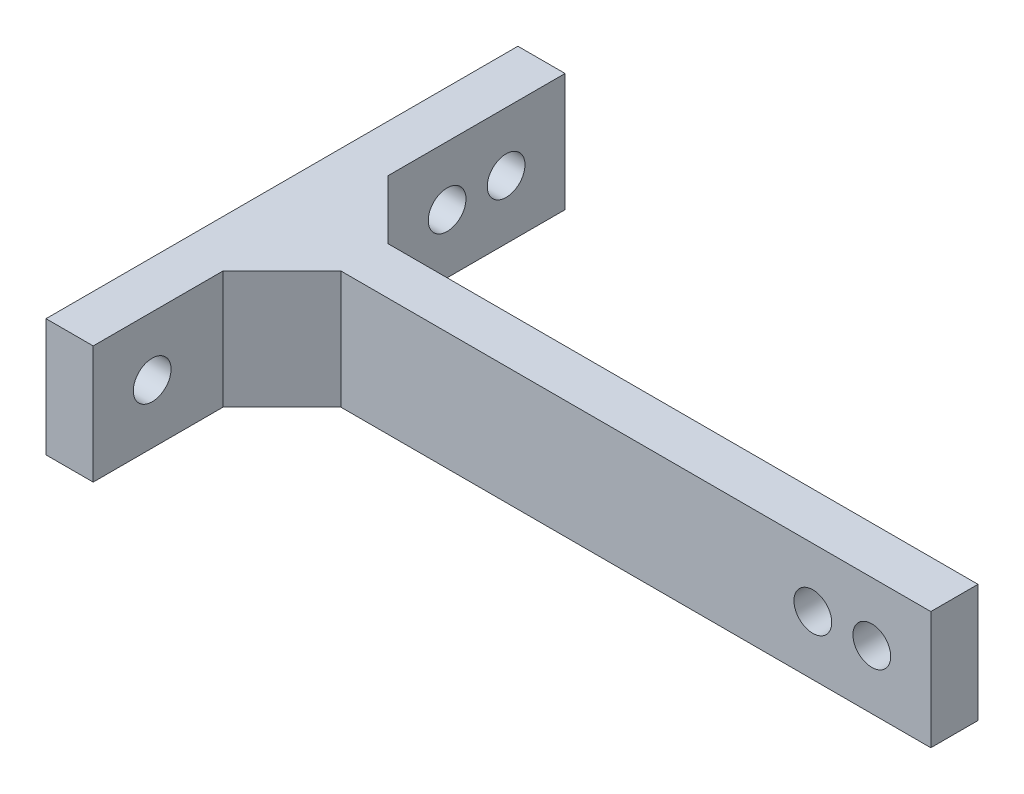
from build123d import *

# Parameters (mm, degrees)
SKETCH_1_W          = 55
SKETCH_1_H          = 10
EXTRUDE_1_DEPTH     = 4
SKETCH_2_W          = 40
SKETCH_2_H          = 10
EXTRUDE_2_DEPTH     = 4
EXTRUDE_3_DEPTH     = 10
EXTRUDE_5_DEPTH     = 10
SKETCH_4_R          = 1.6
CUT_EXTRUDE_1_DEPTH = 5
SKETCH_7_R          = 1.6
CUT_EXTRUDE_2_DEPTH = 4


with BuildPart() as part:
    # ｽｹｯﾁ1 → ﾎﾞｽ - 押し出し1 (new body)
    with BuildSketch(Plane.XY):
        with Locations((4.479686187, -2.540603248)):
            Rectangle(SKETCH_1_W, SKETCH_1_H)
    extrude(amount=EXTRUDE_1_DEPTH)

    # ｽｹｯﾁ2 → ﾎﾞｽ - 押し出し2 (add)
    with BuildSketch(Plane.ZY.offset(23.020313813)):
        with Locations((0, -2.540603248)):
            Rectangle(SKETCH_2_W, SKETCH_2_H)
    extrude(amount=EXTRUDE_2_DEPTH)

    # ｽｹｯﾁ3 → ﾎﾞｽ - 押し出し3 (add)
    with BuildSketch(Plane(origin=(0, 2.459396752, 0), x_dir=(1, 0, 0), z_dir=(0, 1, 0))):
        Polygon((-23.020313813, 5), (-18.020313813, 0), (-23.020313813, 0), align=None)
    extrude(amount=-EXTRUDE_3_DEPTH)

    # ｽｹｯﾁ6 → ﾎﾞｽ - 押し出し5 (add)
    with BuildSketch(Plane.XZ.offset(7.540603248)):
        Polygon((-23.020313813, 9), (-18.020313813, 4), (31.979686187, 4), (31.979686187, 0), (-18.020313813, 0), (-23.020313813, -5), (-23.020313813, -20), (-27.020313813, -20), (-27.020313813, 20), (-23.020313813, 20), align=None)
    extrude(amount=-EXTRUDE_5_DEPTH)

    # ｽｹｯﾁ4 → ｶｯﾄ - 押し出し1 (cut)
    with BuildSketch(Plane.XY.offset(4)):
        with Locations((26.979686187, -2.540603248)):
            Circle(SKETCH_4_R)
        with Locations((21.979686187, -2.540603248)):
            Circle(SKETCH_4_R)
    extrude(amount=-CUT_EXTRUDE_1_DEPTH, mode=Mode.SUBTRACT)

    # ｽｹｯﾁ7 → ｶｯﾄ - 押し出し2 (cut)
    with BuildSketch(Plane(origin=(-23.020313813, 0, 0), x_dir=(0, 0, -1), z_dir=(1, 0, 0))):
        with Locations((-15, -2.540603248)):
            Circle(SKETCH_7_R)
        with Locations((10, -2.540603248)):
            Circle(SKETCH_7_R)
        with Locations((15, -2.540603248)):
            Circle(SKETCH_7_R)
    extrude(amount=-CUT_EXTRUDE_2_DEPTH, mode=Mode.SUBTRACT)


solid = part.part
